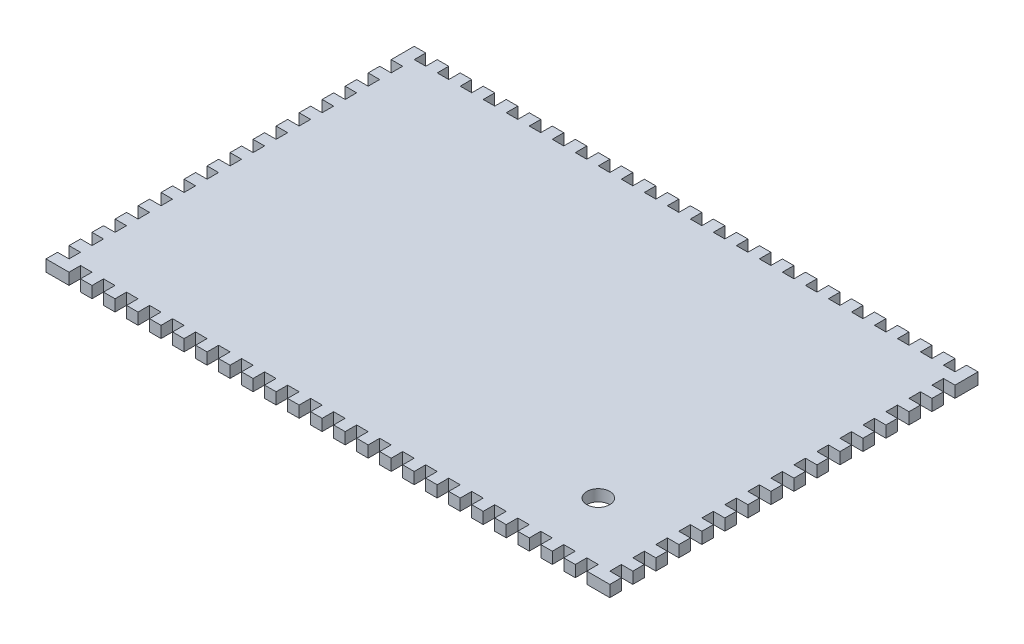
from build123d import *

# Parameters (mm, degrees)
CROQUIS1_R              = 5
SALIENTE_EXTRUIR1_DEPTH = 5


with BuildPart() as part:
    # Croquis1 → Saliente-Extruir1 (new body)
    with BuildSketch(Plane(origin=(0, 0, 0), x_dir=(1, 0, 0), z_dir=(0, 1, 0))):
        Polygon((5, 110), (0, 110), (0, 115), (5, 115), (5, 120), (0, 120), (0, 125), (5, 125), (5, 130), (0, 130), (0, 135), (5, 135), (5, 140), (0, 140), (0, 145), (5, 145), (5, 150), (0, 150), (0, 160), (5, 160), (5, 155), (10, 155), (10, 160), (15, 160), (15, 155), (20, 155), (20, 160), (25, 160), (25, 155), (30, 155), (30, 160), (35, 160), (35, 155), (40, 155), (40, 160), (45, 160), (45, 155), (50, 155), (50, 160), (55, 160), (55, 155), (60, 155), (60, 160), (65, 160), (65, 155), (70, 155), (70, 160), (75, 160), (75, 155), (80, 155), (80, 160), (85, 160), (85, 155), (90, 155), (90, 160), (95, 160), (95, 155), (100, 155), (100, 160), (105, 160), (105, 155), (110, 155), (110, 160), (115, 160), (115, 155), (120, 155), (120, 160), (125, 160), (125, 155), (130, 155), (130, 160), (135, 160), (135, 155), (140, 155), (140, 160), (145, 160), (145, 155), (150, 155), (150, 160), (155, 160), (155, 155), (160, 155), (160, 160), (165, 160), (165, 155), (170, 155), (170, 160), (175, 160), (175, 155), (180, 155), (180, 160), (185, 160), (185, 155), (190, 155), (190, 160), (195, 160), (195, 155), (200, 155), (200, 160), (205, 160), (205, 155), (210, 155), (210, 160), (215, 160), (215, 155), (220, 155), (220, 160), (225, 160), (225, 155), (230, 155), (230, 160), (235, 160), (235, 155), (240, 155), (240, 160), (245, 160), (245, 150), (240, 150), (240, 145), (245, 145), (245, 140), (240, 140), (240, 135), (245, 135), (245, 130), (240, 130), (240, 125), (245, 125), (245, 120), (240, 120), (240, 115), (245, 115), (245, 110), (240, 110), (240, 105), (245, 105), (245, 100), (240, 100), (240, 95), (245, 95), (245, 90), (240, 90), (240, 85), (245, 85), (245, 80), (240, 80), (240, 75), (245, 75), (245, 70), (240, 70), (240, 65), (245, 65), (245, 60), (240, 60), (240, 55), (245, 55), (245, 50), (240, 50), (240, 45), (245, 45), (245, 40), (240, 40), (240, 35), (245, 35), (245, 30), (240, 30), (240, 25), (245, 25), (245, 20), (240, 20), (240, 15), (245, 15), (245, 10), (240, 10), (240, 5), (245, 5), (245, 0), (235, 0), (235, 5), (230, 5), (230, 0), (225, 0), (225, 5), (220, 5), (220, 0), (215, 0), (215, 5), (210, 5), (210, 0), (205, 0), (205, 5), (200, 5), (200, 0), (195, 0), (195, 5), (190, 5), (190, 0), (185, 0), (185, 5), (180, 5), (180, 0), (175, 0), (175, 5), (170, 5), (170, 0), (165, 0), (165, 5), (160, 5), (160, 0), (155, 0), (155, 5), (150, 5), (150, 0), (145, 0), (145, 5), (140, 5), (140, 0), (135, 0), (135, 5), (130, 5), (130, 0), (125, 0), (125, 5), (120, 5), (120, 0), (115, 0), (115, 5), (110, 5), (110, 0), (105, 0), (105, 5), (100, 5), (100, 0), (95, 0), (95, 5), (90, 5), (90, 0), (85, 0), (85, 5), (80, 5), (80, 0), (75, 0), (75, 5), (70, 5), (70, 0), (65, 0), (65, 5), (60, 5), (60, 0), (55, 0), (55, 5), (50, 5), (50, 0), (45, 0), (45, 5), (40, 5), (40, 0), (35, 0), (35, 5), (30, 5), (30, 0), (25, 0), (25, 5), (20, 5), (20, 0), (15, 0), (15, 5), (10, 5), (10, 0), (5, 0), (0, 0), (0, 5), (5, 5), (5, 10), (0, 10), (0, 15), (5, 15), (5, 20), (0, 20), (0, 25), (5, 25), (5, 30), (0, 30), (0, 35), (5, 35), (5, 40), (0, 40), (0, 45), (5, 45), (5, 50), (0, 50), (0, 55), (5, 55), (5, 60), (0, 60), (0, 65), (5, 65), (5, 70), (0, 70), (0, 75), (5, 75), (5, 80), (0, 80), (0, 85), (5, 85), (5, 90), (0, 90), (0, 95), (5, 95), (5, 100), (0, 100), (0, 105), (5, 105), align=None)
        with Locations((210, 30)):
            Circle(CROQUIS1_R, mode=Mode.SUBTRACT)
    extrude(amount=SALIENTE_EXTRUIR1_DEPTH)


solid = part.part
